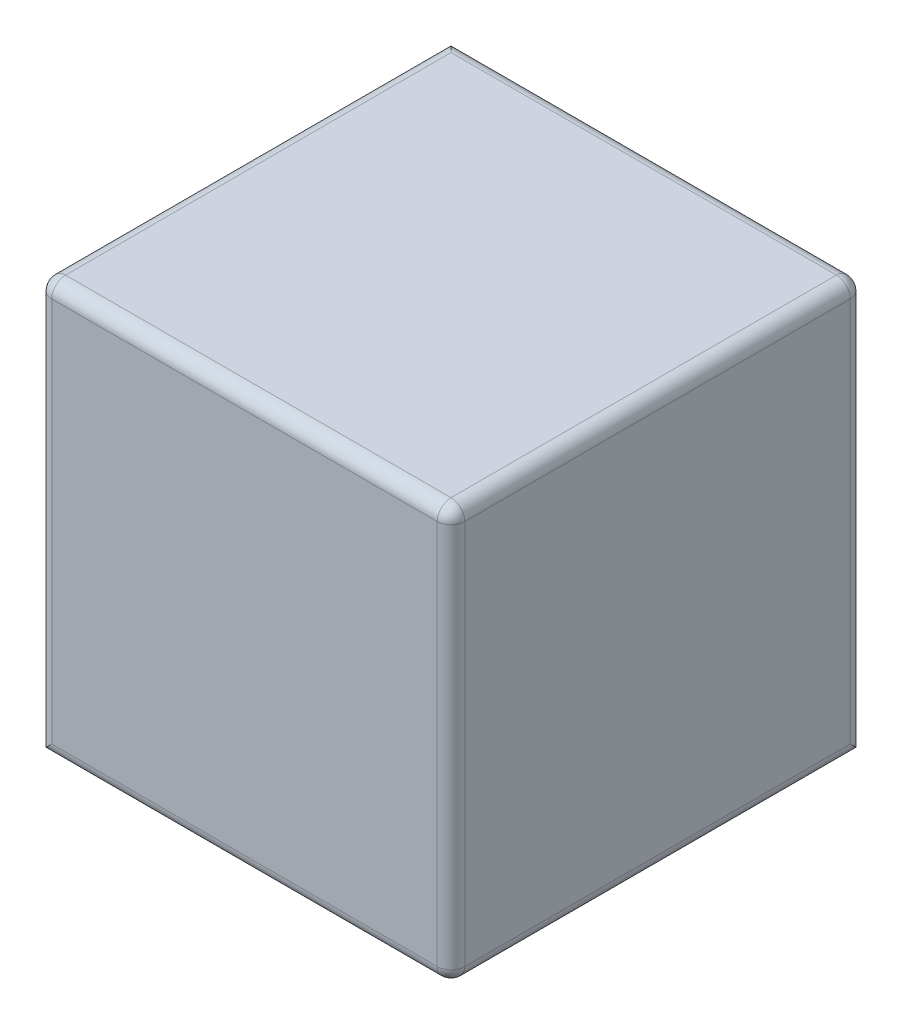
from build123d import *

# Parameters (mm, degrees)
SKETCH1_W           = 300
SKETCH1_H           = 300
BOSS_EXTRUDE1_DEPTH = 300
FILLET1_R           = 10


with BuildPart() as part:
    # Sketch1 → Boss-Extrude1 (new body)
    with BuildSketch(Plane.XY):
        Rectangle(SKETCH1_W, SKETCH1_H)
    extrude(amount=BOSS_EXTRUDE1_DEPTH)

    # Fillet1
    fillet1_edges = [part.edges().sort_by_distance(p)[0] for p in [
        (-150, 0, 300),
        (0, -150, 300),
        (150, 0, 300),
        (0, 150, 0),
        (150, 0, 0),
        (150, -150, 150),
        (-150, 150, 150),
        (150, 150, 150),
        (0, 150, 300),
    ]]
    fillet(fillet1_edges, radius=FILLET1_R)


solid = part.part
